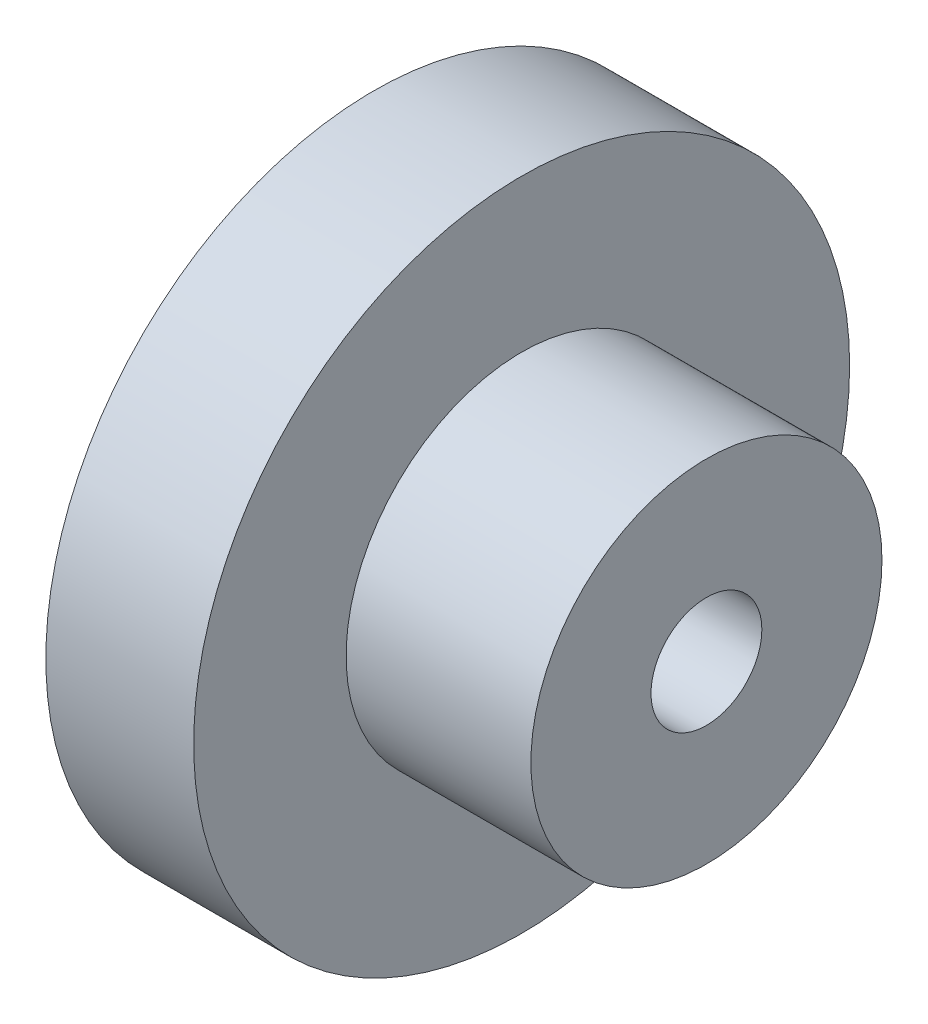
from build123d import *

# Parameters (mm, degrees)
SKETCH1_R           = 8.875
BOSS_EXTRUDE1_DEPTH = 4
SKETCH2_R           = 4.75
BOSS_EXTRUDE2_DEPTH = 5
SKETCH3_R           = 1.5
CUT_EXTRUDE1_DEPTH  = 10


with BuildPart() as part:
    # Sketch1 → Boss-Extrude1 (new body)
    with BuildSketch(Plane(origin=(0, 0, 0), x_dir=(0, 0, -1), z_dir=(1, 0, 0))):
        Circle(SKETCH1_R)
    extrude(amount=BOSS_EXTRUDE1_DEPTH)

    # Sketch2 → Boss-Extrude2 (add)
    with BuildSketch(Plane(origin=(4, 0, 0), x_dir=(0, 0, -1), z_dir=(1, 0, 0))):
        Circle(SKETCH2_R)
    extrude(amount=BOSS_EXTRUDE2_DEPTH)

    # Sketch3 → Cut-Extrude1 (cut, through all)
    with BuildSketch(Plane(origin=(9, 0, 0), x_dir=(0, 0, -1), z_dir=(1, 0, 0))):
        Circle(SKETCH3_R)
    extrude(amount=-CUT_EXTRUDE1_DEPTH, mode=Mode.SUBTRACT)


solid = part.part
